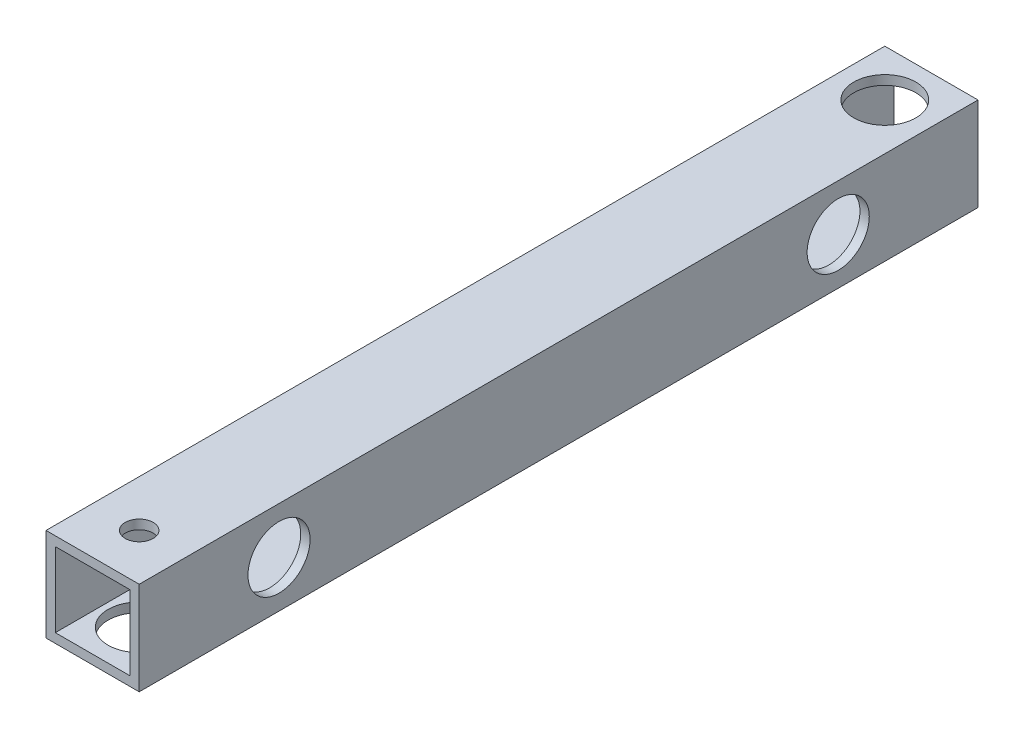
from build123d import *

# Parameters (mm, degrees)
SKETCH_1_W          = 15
SKETCH_1_H          = 15
SKETCH_1_W_2        = 12
SKETCH_1_H_2        = 12
EXTRUDE_1_DEPTH     = 135
SKETCH_2_R          = 2.7
CUT_EXTRUDE_1_DEPTH = 25
SKETCH_3_R          = 2.7
SKETCH_3_R_2        = 2.25
CUT_EXTRUDE_2_DEPTH = 25
SKETCH_4_R          = 5
CUT_EXTRUDE_3_DEPTH = 10
SKETCH_5_R          = 5
CUT_EXTRUDE_4_DEPTH = 10
SKETCH_6_R          = 5
CUT_EXTRUDE_5_DEPTH = 10


with BuildPart() as part:
    # ｽｹｯﾁ1 → ﾎﾞｽ - 押し出し1 (new body)
    with BuildSketch(Plane.XY):
        Rectangle(SKETCH_1_W, SKETCH_1_H)
        Rectangle(SKETCH_1_W_2, SKETCH_1_H_2, mode=Mode.SUBTRACT)
    extrude(amount=EXTRUDE_1_DEPTH)

    # ｽｹｯﾁ2 → ｶｯﾄ - 押し出し1 (cut)
    with BuildSketch(Plane(origin=(7.5, 0, 0), x_dir=(0, 0, -1), z_dir=(1, 0, 0))):
        with Locations((-112.5, 0)):
            Circle(SKETCH_2_R)
        with Locations((-22.5, 0)):
            Circle(SKETCH_2_R)
    extrude(amount=-CUT_EXTRUDE_1_DEPTH, mode=Mode.SUBTRACT)

    # ｽｹｯﾁ3 → ｶｯﾄ - 押し出し2 (cut)
    with BuildSketch(Plane(origin=(0, 7.5, 0), x_dir=(1, 0, 0), z_dir=(0, 1, 0))):
        with Locations((0, -7.5)):
            Circle(SKETCH_3_R)
        with Locations((0, -127.5)):
            Circle(SKETCH_3_R_2)
    extrude(amount=-CUT_EXTRUDE_2_DEPTH, mode=Mode.SUBTRACT)

    # ｽｹｯﾁ4 → ｶｯﾄ - 押し出し3 (cut)
    with BuildSketch(Plane(origin=(0, 7.5, 0), x_dir=(1, 0, 0), z_dir=(0, 1, 0))):
        with Locations((0, -7.5)):
            Circle(SKETCH_4_R)
    extrude(amount=-CUT_EXTRUDE_3_DEPTH, mode=Mode.SUBTRACT)

    # ｽｹｯﾁ5 → ｶｯﾄ - 押し出し4 (cut)
    with BuildSketch(Plane(origin=(7.5, 0, 0), x_dir=(0, 0, -1), z_dir=(1, 0, 0))):
        with Locations((-22.5, 0)):
            Circle(SKETCH_5_R)
        with Locations((-112.5, 0)):
            Circle(SKETCH_5_R)
    extrude(amount=-CUT_EXTRUDE_4_DEPTH, mode=Mode.SUBTRACT)

    # ｽｹｯﾁ6 → ｶｯﾄ - 押し出し5 (cut)
    with BuildSketch(Plane(origin=(0, -7.5, 0), x_dir=(-1, 0, 0), z_dir=(0, -1, 0))):
        with Locations((0, -127.5)):
            Circle(SKETCH_6_R)
    extrude(amount=-CUT_EXTRUDE_5_DEPTH, mode=Mode.SUBTRACT)


solid = part.part
